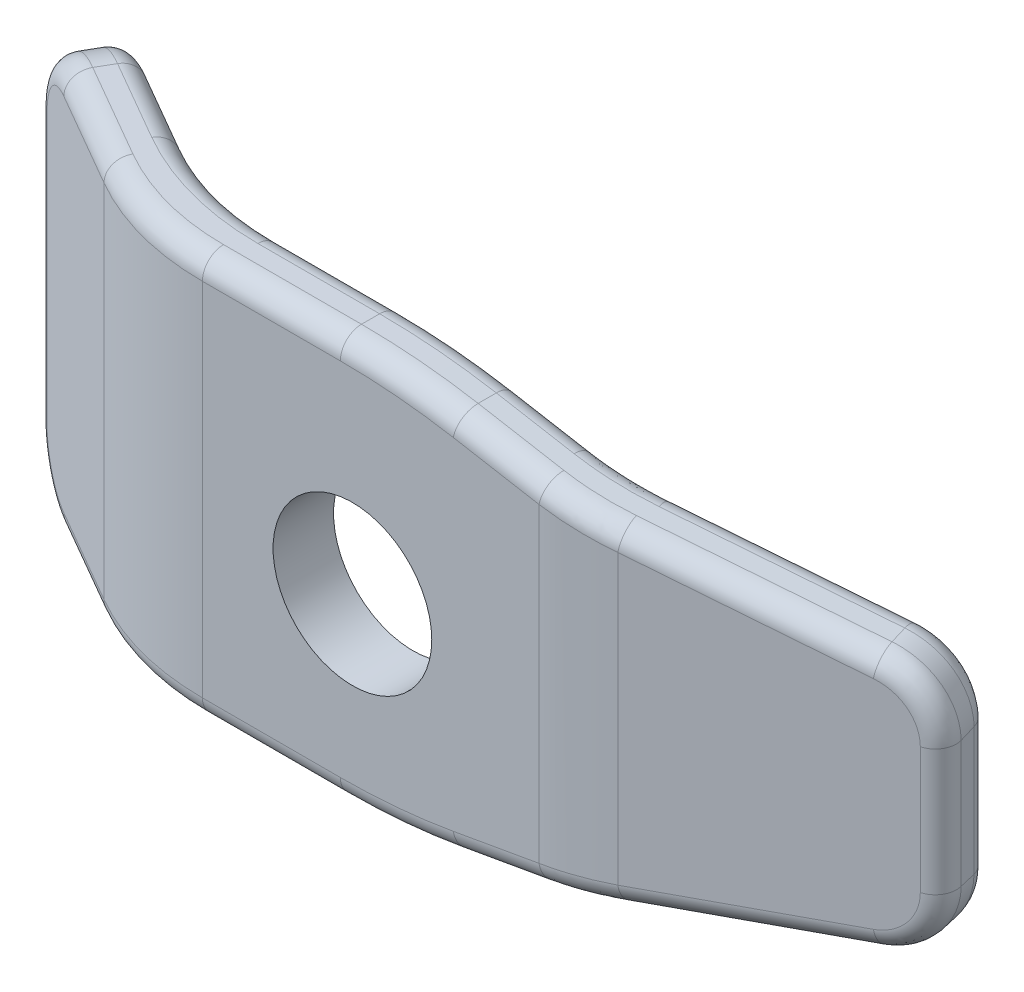
from build123d import *

# Parameters (mm, degrees)
BOSS_EXTRUDE1_DEPTH = 76.2
CUT_EXTRUDE1_DEPTH  = 76.2
SKETCH3_R           = 15
CUT_EXTRUDE2_DEPTH  = 50.8
FILLET1_R           = 50.8
FILLET2_R           = 50.8
FILLET3_R           = 127
FILLET4_R           = 12.7
FILLET5_R           = 4
SCALE1_SCALE        = 0.06


with BuildPart() as part:
    # Sketch1 → Boss-Extrude1 (new body)
    with BuildSketch(Plane(origin=(0, 0, 0), x_dir=(1, 0, 0), z_dir=(0, 1, 0))):
        Polygon((-69.309365325, 21.997045256), (-31.209365325, 0), (48.165634675, 0), (102.140634675, 14.462557661), (105.09893636, 3.422025467), (49.670422722, -11.43), (-34.272024595, -11.43), (-75.024365325, 12.098374891), align=None)
    extrude(amount=BOSS_EXTRUDE1_DEPTH)

    # Sketch2 → Cut-Extrude1 (cut)
    with BuildSketch(Plane.XY.offset(11.43)):
        Polygon((16.527975405, 76.2), (105.09893636, 60.582549876), (105.09893636, 76.2), align=None)
        Polygon((16.527975405, 0), (105.09893636, 15.617450124), (105.09893636, 0), align=None)
    extrude(amount=-CUT_EXTRUDE1_DEPTH, mode=Mode.SUBTRACT)

    # Sketch3 → Cut-Extrude2 (cut)
    with BuildSketch(Plane.XY.offset(11.43)):
        with Locations((7.699199064, 35.178046166)):
            Circle(SKETCH3_R)
    extrude(amount=-CUT_EXTRUDE2_DEPTH, mode=Mode.SUBTRACT)

    # Fillet1
    fillet1_edges = [part.edges().sort_by_distance(p)[0] for p in [
        (-34.272024595, 38.1, 11.43),
        (49.670422722, 38.1, 11.43),
    ]]
    fillet(fillet1_edges, radius=FILLET1_R)

    # Fillet2
    fillet2_edges = [part.edges().sort_by_distance(p)[0] for p in [
        (-31.209365325, 38.1, 0),
        (48.165634675, 38.1, 0),
    ]]
    fillet(fillet2_edges, radius=FILLET2_R)

    # Fillet3
    fillet3_edges = [part.edges().sort_by_distance(p)[0] for p in [
        (16.527975405, 0, 5.715),
        (16.527975405, 76.2, 5.715),
    ]]
    fillet(fillet3_edges, radius=FILLET3_R)

    # Fillet4
    fillet4_edges = [part.edges().sort_by_distance(p)[0] for p in [
        (-72.166865325, 0, -17.047710073),
        (103.619785518, 60.843364078, -8.942291564),
        (103.619785518, 15.356635922, -8.942291564),
        (-72.166865325, 76.2, -17.047710073),
    ]]
    fillet(fillet4_edges, radius=FILLET4_R)

    # Fillet5
    fillet5_edges = [part.edges().sort_by_distance(p)[0] for p in [
        (73.278337302, 66.193380033, -6.728928389),
        (-50.654194523, 0, -11.226477372),
        (-50.654194523, 76.2, -11.226477372),
        (48.106743102, 5.568188762, -0.434380518),
        (48.106743102, 70.631811238, -0.434380518),
        (-30.745553841, 0, -1.730968025),
        (-30.745553841, 76.2, -1.730968025),
        (-6.090315606, 0, 0),
        (35.226354773, 72.902971222, 11.43),
        (16.485694467, 75.716726658, 11.43),
        (16.485694467, 0.483273342, 11.43),
        (34.473960749, 73.035638588, 0),
        (-6.090315606, 76.2, 0),
        (16.485694467, 75.716726658, 0),
        (16.485694467, 0.483273342, 0),
        (102.140634675, 38.1, -14.462557661),
        (105.09893636, 38.1, -3.422025467),
        (75.509882168, 65.799898464, 4.506337709),
        (102.206913339, 18.151288634, -2.647110234),
        (102.206913339, 58.048711366, -2.647110234),
        (73.278337302, 10.006619967, -6.728928389),
        (99.248611653, 17.62966023, -13.687642428),
        (99.248611653, 58.57033977, -13.687642428),
        (-55.043024158, 76.2, -0.562142189),
        (-55.043024158, 0, -0.562142189),
        (-75.024365325, 38.1, -12.098374891),
        (-71.80297263, 3.719743879, -10.238502951),
        (-71.80297263, 72.480256121, -10.238502951),
        (-69.309365325, 38.1, -21.997045256),
        (-66.08797263, 3.719743879, -20.137173317),
        (-66.08797263, 72.480256121, -20.137173317),
        (75.509882168, 10.400101536, 4.506337709),
        (35.226354773, 3.297028778, 11.43),
        (49.611531149, 5.833523495, 10.995619482),
        (-7.621645241, 76.2, 11.43),
        (-7.621645241, 0, 11.43),
        (49.611531149, 70.366476505, 10.995619482),
        (-33.80821311, 0, 9.699031975),
        (-33.80821311, 76.2, 9.699031975),
        (34.473960749, 3.164361412, 0),
    ]]
    fillet(fillet5_edges, radius=FILLET5_R)


with BuildPart() as part_1:
    # Scale1: scaled about (7.509399515, 38.279312086, 0.733186498)
    add(part.part.scale(SCALE1_SCALE).moved(Location((7.058835544, 35.982553361, 0.689195308))))


solid = part_1.part
